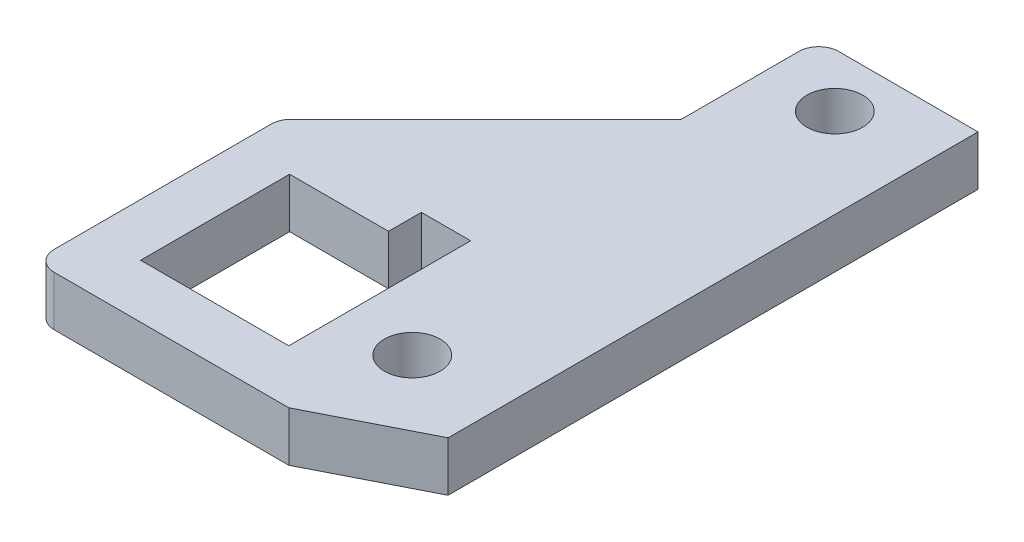
from build123d import *

# Parameters (mm, degrees)
SKETCH1_R           = 1.778
BOSS_EXTRUDE1_DEPTH = 3.175


with BuildPart() as part:
    # Sketch1 → Boss-Extrude1 (new body)
    with BuildSketch(Plane.XZ):
        with BuildLine():
            Line((0, -1.27), (0, -15.096211993))
            ThreePointArc((0, -15.096211993), (0.096672994, -15.582219953), (0.371974388, -15.994237606))
            Line((0.371974388, -15.994237606), (12.811233382, -28.4334966))
            Line((12.811233382, -28.4334966), (12.811233382, -35.9325926))
            ThreePointArc((12.811233382, -35.9325926), (13.18320777, -36.830618212), (14.081233382, -37.2025926))
            Line((14.081233382, -37.2025926), (22.963359382, -37.2025926))
            Line((22.963359382, -37.2025926), (22.963359382, -3.420573773))
            Line((22.963359382, -3.420573773), (16.223955667, 0))
            Line((16.223955667, 0), (1.27, 0))
            ThreePointArc((1.27, 0), (0.371974388, -0.371974388), (0, -1.27))
        make_face()
        with Locations((17.255979382, -33.7812126)):
            Circle(SKETCH1_R, mode=Mode.SUBTRACT)
        with Locations((17.255979382, -6.840444237)):
            Circle(SKETCH1_R, mode=Mode.SUBTRACT)
        Polygon((9.66216, -12.92098), (3.35788, -12.92098), (3.35788, -3.42138), (12.80414, -3.42138), (12.80414, -15.01648), (9.66216, -15.01648), align=None, mode=Mode.SUBTRACT)
    extrude(amount=-BOSS_EXTRUDE1_DEPTH)


solid = part.part
